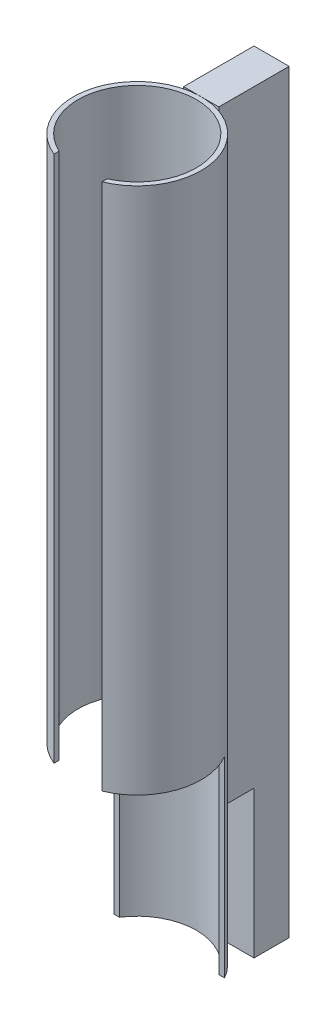
from build123d import *

# Parameters (mm, degrees)
ESQUISSE1_R                  = 40
ESQUISSE1_R_2                = 37
BOSS_EXTRU_1_DEPTH           = 450
ENL_V_MAT_EXTRU_1_DEPTH      = 454.541618818
ENL_V_MAT_EXTRU_1_DEPTH_BACK = 20
ESQUISSE2_W                  = 80
ESQUISSE2_H                  = 120
BOSS_EXTRU_2_DEPTH           = 11
ESQUISSE4_W                  = 30
ESQUISSE4_H                  = 450
ENL_V_MAT_EXTRU_2_DEPTH      = 460.517137874


with BuildPart() as part:
    # Esquisse1 → Boss.-Extru.1 (new body)
    with BuildSketch(Plane(origin=(0, 0, 0), x_dir=(1, 0, 0), z_dir=(0, 1, 0))):
        Circle(ESQUISSE1_R)
        Circle(ESQUISSE1_R_2, mode=Mode.SUBTRACT)
    extrude(amount=BOSS_EXTRU_1_DEPTH)

    # Esquisse2 → Enlèv. mat.-Extru.1 (cut, two sides: drawn at the far end of the back side and taken through both)
    with BuildSketch(Plane.XY.offset(-ENL_V_MAT_EXTRU_1_DEPTH_BACK)):
        with Locations((0, 60)):
            Rectangle(ESQUISSE2_W, ESQUISSE2_H)
    extrude(amount=ENL_V_MAT_EXTRU_1_DEPTH + ENL_V_MAT_EXTRU_1_DEPTH_BACK, mode=Mode.SUBTRACT)

    # Esquisse4 → Enlèv. mat.-Extru.2 (cut, through all)
    with BuildSketch(Plane.XY):
        with Locations((0, 225)):
            Rectangle(ESQUISSE4_W, ESQUISSE4_H)
    extrude(amount=ENL_V_MAT_EXTRU_2_DEPTH, mode=Mode.SUBTRACT)


with BuildPart() as body_2:
    # Esquisse3 → Boss.-Extru.2 (new, symmetric)
    with BuildSketch(Plane(origin=(0, 0, 0), x_dir=(0, 0, -1), z_dir=(1, 0, 0))):
        Polygon((62, -22), (84, -22), (84, 450), (40, 450), (40, 70), (62, 70), align=None)
    extrude(amount=BOSS_EXTRU_2_DEPTH, both=True)


solid = Compound([part.part, body_2.part])
